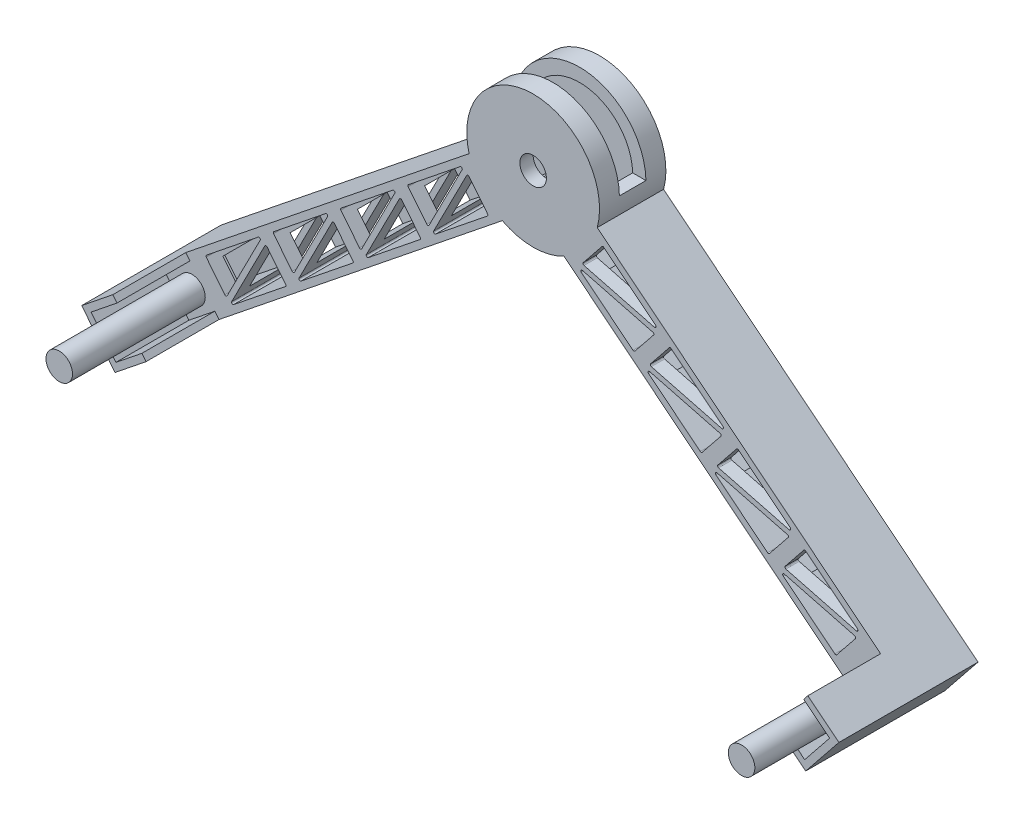
from build123d import *

# Parameters (mm, degrees)
BOSS_EXTRUDE1_DEPTH = 50
SHELL1_T            = -10
SKETCH2_R           = 10
CUT_EXTRUDE1_DEPTH  = 50
SKETCH5_W           = 100
SKETCH5_H           = 20
CUT_EXTRUDE2_DEPTH  = 50
SKETCH6_W           = 30
SKETCH6_H           = 20
CUT_EXTRUDE3_DEPTH  = 50
SKETCH7_W           = 4.757319218
SKETCH7_H           = 40
BOSS_EXTRUDE2_DEPTH = 5
BOSS_EXTRUDE3_DEPTH = 100
BOSS_EXTRUDE4_DEPTH = 54.757319
SKETCH12_W          = 9.972991782
SKETCH12_H          = 40
BOSS_EXTRUDE5_DEPTH = 5
BOSS_EXTRUDE6_DEPTH = 95
BOSS_EXTRUDE7_DEPTH = 54.972992
CUT_EXTRUDE4_DEPTH  = 95
SKETCH16_R          = 10
BOSS_EXTRUDE8_DEPTH = 100
SKETCH18_R          = 10
BOSS_EXTRUDE9_DEPTH = 100


with BuildPart() as part:
    # Sketch1 → Boss-Extrude1 (new body)
    with BuildSketch(Plane.XY):
        with BuildLine():
            Line((-187.116228399, 0), (45.852765534, 186.921335305))
            ThreePointArc((45.852765534, 186.921335305), (94.111946316, 250), (142.371127099, 186.921335305))
            Line((142.371127099, 186.921335305), (375.340121031, 0))
            Line((375.340121031, 0), (350.307747828, -31.199043123))
            Line((350.307747828, -31.199043123), (117.338753895, 155.722292181))
            ThreePointArc((117.338753895, 155.722292181), (94.111946316, 150), (70.885138737, 155.722292181))
            Line((70.885138737, 155.722292181), (-162.083855196, -31.199043123))
            Line((-162.083855196, -31.199043123), (-187.116228399, 0))
        make_face()
    extrude(amount=BOSS_EXTRUDE1_DEPTH)

    # Shell1
    shell1_openings = [part.faces().sort_by_distance(p)[0] for p in [
        (-174.600041797, -15.599521562, 25),
    ]]
    offset(amount=SHELL1_T, openings=shell1_openings, kind=Kind.INTERSECTION)

    # Sketch2 → Cut-Extrude1 (cut)
    with BuildSketch(Plane.XY.offset(50)):
        with Locations((94.111946316, 200)):
            Circle(SKETCH2_R)
    extrude(amount=-CUT_EXTRUDE1_DEPTH, mode=Mode.SUBTRACT)

    # Sketch5 → Cut-Extrude2 (cut)
    with BuildSketch(Plane(origin=(0, 251, 0), x_dir=(1, 0, 0), z_dir=(0, 1, 0))):
        with Locations((94.111946316, -25)):
            Rectangle(SKETCH5_W, SKETCH5_H)
    extrude(amount=-CUT_EXTRUDE2_DEPTH, mode=Mode.SUBTRACT)

    # Sketch6 → Cut-Extrude3 (cut)
    with BuildSketch(Plane(origin=(228.342922838, -183.209633711, 0), x_dir=(0, 0, -1), z_dir=(0.779976078, -0.62580933, 0))):
        with Locations((-25, 214.891349694)):
            Rectangle(SKETCH6_W, SKETCH6_H)
    extrude(amount=-CUT_EXTRUDE3_DEPTH, mode=Mode.SUBTRACT)

    # Sketch7 → Boss-Extrude2 (add)
    with BuildSketch(Plane(origin=(228.342922838, -183.209633711, 0), x_dir=(0, 0, -1), z_dir=(0.779976078, -0.62580933, 0))):
        with Locations((-2.378659609, 214.891349694)):
            Rectangle(SKETCH7_W, SKETCH7_H)
    extrude(amount=BOSS_EXTRUDE2_DEPTH)

    # Sketch8 → Boss-Extrude3 (add)
    with BuildSketch(Plane.XY.offset(4.757319218)):
        Polygon((375.340121031, 0), (350.307747828, -31.199043123), (354.207628218, -34.328089774), (379.240001422, -3.12904665), align=None)
    extrude(amount=BOSS_EXTRUDE3_DEPTH)

    # Sketch9 → Boss-Extrude4 (add)
    with BuildSketch(Plane.XY.offset(50)):
        Polygon((375.340121031, 0), (355.840719079, 15.645233252), (352.711672429, 11.745352862), (372.211074381, -3.89988039), align=None)
        Polygon((350.307747828, -31.199043123), (330.808345876, -15.553809872), (333.937392526, -11.653929481), (353.436794478, -27.299162733), align=None)
    extrude(amount=BOSS_EXTRUDE4_DEPTH)

    # Sketch12 → Boss-Extrude5 (add)
    with BuildSketch(Plane(origin=(-113.834530627, -91.334482368, 0), x_dir=(0, 0, 1), z_dir=(-0.779976078, -0.62580933, 0))):
        with Locations((4.986495891, 97.099081541)):
            Rectangle(SKETCH12_W, SKETCH12_H)
    extrude(amount=BOSS_EXTRUDE5_DEPTH)

    # Sketch13 → Boss-Extrude6 (add)
    with BuildSketch(Plane.XY.offset(9.972991782)):
        Polygon((-162.083855196, -31.199043123), (-187.116228399, 0), (-191.016108789, -3.12904665), (-165.983735586, -34.328089774), align=None)
    extrude(amount=BOSS_EXTRUDE6_DEPTH)

    # Sketch14 → Boss-Extrude7 (add)
    with BuildSketch(Plane.XY.offset(50)):
        Polygon((-187.116228399, 0), (-167.616826447, 15.645233252), (-164.487779796, 11.745352862), (-183.987181748, -3.89988039), align=None)
        Polygon((-162.083855196, -31.199043123), (-165.212901846, -27.299162733), (-145.713499894, -11.653929481), (-142.584453244, -15.553809872), align=None)
    extrude(amount=BOSS_EXTRUDE7_DEPTH)

    # Sketch15 → Cut-Extrude4 (cut)
    with BuildSketch(Plane.XY.offset(50)):
        with BuildLine():
            Line((-152.162329295, 20.352516735), (-138.10997348, 2.838394062))
            ThreePointArc((-138.10997348, 2.838394062), (-137.22835262, 2.469382635), (-136.439576622, 3.009065133))
            Line((-136.439576622, 3.009065133), (-111.493128533, 51.813654309))
            ThreePointArc((-111.493128533, 51.813654309), (-111.751978524, 53.044110786), (-113.009358643, 53.048768647))
            Line((-113.009358643, 53.048768647), (-152.008162547, 21.758302143))
            ThreePointArc((-152.008162547, 21.758302143), (-152.376393612, 21.087338418), (-152.162329295, 20.352516735))
        make_face()
        with BuildLine():
            Line((-106.340954265, 50.007446869), (-92.28859845, 32.493324197))
            ThreePointArc((-92.28859845, 32.493324197), (-92.074534133, 31.758502514), (-92.442765198, 31.087538789))
            Line((-92.442765198, 31.087538789), (-131.441569102, -0.202927715))
            ThreePointArc((-131.441569102, -0.202927715), (-132.698949221, -0.198269855), (-132.957799212, 1.032186622))
            Line((-132.957799212, 1.032186622), (-108.011351123, 49.836775799))
            ThreePointArc((-108.011351123, 49.836775799), (-107.222575125, 50.376458296), (-106.340954265, 50.007446869))
        make_face()
        with BuildLine():
            Line((-62.310913567, 93.726375102), (-101.309717471, 62.435908598))
            ThreePointArc((-101.309717471, 62.435908598), (-101.677948536, 61.764944873), (-101.463884219, 61.03012319))
            Line((-101.463884219, 61.03012319), (-87.411528404, 43.516000517))
            ThreePointArc((-87.411528404, 43.516000517), (-86.529907544, 43.14698909), (-85.741131546, 43.686671588))
            Line((-85.741131546, 43.686671588), (-60.794683457, 92.491260764))
            ThreePointArc((-60.794683457, 92.491260764), (-61.053533448, 93.721717241), (-62.310913567, 93.726375102))
        make_face()
        with BuildLine():
            Line((-82.259354137, 41.709793077), (-57.312906048, 90.514382254))
            ThreePointArc((-57.312906048, 90.514382254), (-56.524130049, 91.054064751), (-55.64250919, 90.685053325))
            Line((-55.64250919, 90.685053325), (-41.590153374, 73.170930652))
            ThreePointArc((-41.590153374, 73.170930652), (-41.376089058, 72.436108969), (-41.744320122, 71.765145244))
            Line((-41.744320122, 71.765145244), (-80.743124027, 40.47467874))
            ThreePointArc((-80.743124027, 40.47467874), (-82.000504146, 40.4793366), (-82.259354137, 41.709793077))
        make_face()
        with BuildLine():
            Line((-11.612468491, 134.403981557), (-50.611272396, 103.113515053))
            ThreePointArc((-50.611272396, 103.113515053), (-50.979503461, 102.442551328), (-50.765439144, 101.707729645))
            Line((-50.765439144, 101.707729645), (-36.713083328, 84.193606972))
            ThreePointArc((-36.713083328, 84.193606972), (-35.831462469, 83.824595545), (-35.042686471, 84.364278043))
            Line((-35.042686471, 84.364278043), (-10.096238381, 133.168867219))
            ThreePointArc((-10.096238381, 133.168867219), (-10.355088372, 134.399323696), (-11.612468491, 134.403981557))
        make_face()
        with BuildLine():
            Line((-31.560909061, 82.387399532), (-6.614460972, 131.191988709))
            ThreePointArc((-6.614460972, 131.191988709), (-5.825684974, 131.731671206), (-4.944064114, 131.36265978))
            Line((-4.944064114, 131.36265978), (9.108291701, 113.848537107))
            ThreePointArc((9.108291701, 113.848537107), (9.322356018, 113.113715424), (8.954124953, 112.442751699))
            Line((8.954124953, 112.442751699), (-30.044678951, 81.152285195))
            ThreePointArc((-30.044678951, 81.152285195), (-31.30205907, 81.156943055), (-31.560909061, 82.387399532))
        make_face()
        with BuildLine():
            Line((39.085976584, 175.081588012), (0.08717268, 143.791121508))
            ThreePointArc((0.08717268, 143.791121508), (-0.281058385, 143.120157783), (-0.066994068, 142.3853361))
            Line((-0.066994068, 142.3853361), (13.985361747, 124.871213427))
            ThreePointArc((13.985361747, 124.871213427), (14.866982607, 124.502202), (15.655758605, 125.041884498))
            Line((15.655758605, 125.041884498), (40.602206694, 173.846473674))
            ThreePointArc((40.602206694, 173.846473674), (40.343356703, 175.076930151), (39.085976584, 175.081588012))
        make_face()
        with BuildLine():
            Line((19.137536015, 123.065005987), (44.083984104, 171.869595164))
            ThreePointArc((44.083984104, 171.869595164), (44.872760102, 172.409277661), (45.754380962, 172.040266235))
            Line((45.754380962, 172.040266235), (59.806736777, 154.526143562))
            ThreePointArc((59.806736777, 154.526143562), (60.020801094, 153.791321879), (59.652570029, 153.120358154))
            Line((59.652570029, 153.120358154), (20.653766124, 121.82989165))
            ThreePointArc((20.653766124, 121.82989165), (19.396386006, 121.83454951), (19.137536015, 123.065005987))
        make_face()
        with BuildLine():
            Line((322.863560685, -1.486813452), (336.9159165, 16.027309221))
            ThreePointArc((336.9159165, 16.027309221), (337.085087888, 16.967950393), (336.387284466, 17.621016361))
            Line((336.387284466, 17.621016361), (283.336124747, 31.397360193))
            ThreePointArc((283.336124747, 31.397360193), (282.191012363, 30.877991261), (282.458971372, 29.649486304))
            Line((282.458971372, 29.649486304), (321.457775277, -1.6409802))
            ThreePointArc((321.457775277, -1.6409802), (322.19259696, -1.855044517), (322.863560685, -1.486813452))
        make_face()
        with BuildLine():
            Line((338.439741637, 23.196354627), (299.440937733, 54.486821131))
            ThreePointArc((299.440937733, 54.486821131), (298.70611605, 54.700885448), (298.035152325, 54.332654383))
            Line((298.035152325, 54.332654383), (283.982796509, 36.818531711))
            ThreePointArc((283.982796509, 36.818531711), (283.813625122, 35.877890538), (284.511428543, 35.22482457))
            Line((284.511428543, 35.22482457), (337.562588263, 21.448480739))
            ThreePointArc((337.562588263, 21.448480739), (338.707700647, 21.967849671), (338.439741637, 23.196354627))
        make_face()
        with BuildLine():
            Line((233.814614905, 75.901122051), (286.865774625, 62.124778219))
            ThreePointArc((286.865774625, 62.124778219), (288.010887009, 62.644147151), (287.742927999, 63.872652108))
            Line((287.742927999, 63.872652108), (248.744124095, 95.163118612))
            ThreePointArc((248.744124095, 95.163118612), (248.009302411, 95.377182929), (247.338338686, 95.008951864))
            Line((247.338338686, 95.008951864), (233.285982871, 77.494829191))
            ThreePointArc((233.285982871, 77.494829191), (233.116811484, 76.554188019), (233.814614905, 75.901122051))
        make_face()
        with BuildLine():
            Line((231.762157734, 70.325783785), (270.760961639, 39.035317281))
            ThreePointArc((270.760961639, 39.035317281), (271.495783322, 38.821252964), (272.166747047, 39.189484029))
            Line((272.166747047, 39.189484029), (286.219102862, 56.703606701))
            ThreePointArc((286.219102862, 56.703606701), (286.388274249, 57.644247874), (285.690470828, 58.297313842))
            Line((285.690470828, 58.297313842), (232.639311109, 72.073657673))
            ThreePointArc((232.639311109, 72.073657673), (231.494198725, 71.554288741), (231.762157734, 70.325783785))
        make_face()
        with BuildLine():
            Line((183.117801267, 116.577419531), (236.168960986, 102.8010757))
            ThreePointArc((236.168960986, 102.8010757), (237.31407337, 103.320444632), (237.046114361, 104.548949589))
            Line((237.046114361, 104.548949589), (198.047310456, 135.839416092))
            ThreePointArc((198.047310456, 135.839416092), (197.312488773, 136.053480409), (196.641525048, 135.685249344))
            Line((196.641525048, 135.685249344), (182.589169233, 118.171126672))
            ThreePointArc((182.589169233, 118.171126672), (182.419997846, 117.230485499), (183.117801267, 116.577419531))
        make_face()
        with BuildLine():
            Line((181.065344096, 111.002081265), (220.064148, 79.711614761))
            ThreePointArc((220.064148, 79.711614761), (220.798969684, 79.497550444), (221.469933409, 79.865781509))
            Line((221.469933409, 79.865781509), (235.522289224, 97.379904182))
            ThreePointArc((235.522289224, 97.379904182), (235.691460611, 98.320545354), (234.99365719, 98.973611322))
            Line((234.99365719, 98.973611322), (181.94249747, 112.749955154))
            ThreePointArc((181.94249747, 112.749955154), (180.797385086, 112.230586222), (181.065344096, 111.002081265))
        make_face()
        with BuildLine():
            Line((132.420987629, 157.253717012), (185.472147348, 143.477373181))
            ThreePointArc((185.472147348, 143.477373181), (186.617259732, 143.996742113), (186.349300723, 145.225247069))
            Line((186.349300723, 145.225247069), (147.350496818, 176.515713573))
            ThreePointArc((147.350496818, 176.515713573), (146.615675135, 176.72977789), (145.94471141, 176.361546825))
            Line((145.94471141, 176.361546825), (131.892355595, 158.847424152))
            ThreePointArc((131.892355595, 158.847424152), (131.723184208, 157.90678298), (132.420987629, 157.253717012))
        make_face()
        with BuildLine():
            Line((130.368530458, 151.678378746), (169.367334362, 120.387912242))
            ThreePointArc((169.367334362, 120.387912242), (170.102156045, 120.173847925), (170.77311977, 120.54207899))
            Line((170.77311977, 120.54207899), (184.825475586, 138.056201662))
            ThreePointArc((184.825475586, 138.056201662), (184.994646973, 138.996842835), (184.296843552, 139.649908803))
            Line((184.296843552, 139.649908803), (131.245683832, 153.426252634))
            ThreePointArc((131.245683832, 153.426252634), (130.100571448, 152.906883702), (130.368530458, 151.678378746))
        make_face()
    extrude(amount=-CUT_EXTRUDE4_DEPTH, mode=Mode.SUBTRACT)

    # Sketch16 → Boss-Extrude8 (add)
    with BuildSketch(Plane.XY.offset(50)):
        with Locations((-162.900400626, -6.212381611)):
            Circle(SKETCH16_R)
    extrude(amount=BOSS_EXTRUDE8_DEPTH)

    # Sketch18 → Boss-Extrude9 (add)
    with BuildSketch(Plane.XY.offset(50)):
        with Locations((351.124293258, -6.212381611)):
            Circle(SKETCH18_R)
    extrude(amount=BOSS_EXTRUDE9_DEPTH)


solid = part.part
